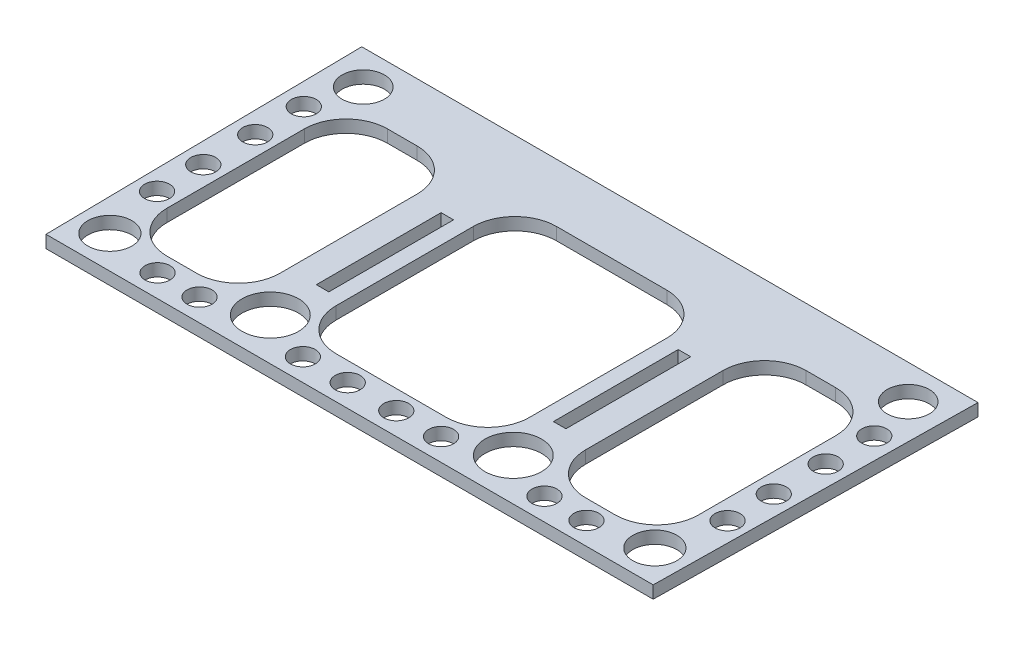
from build123d import *

# Parameters (mm, degrees)
BOSS_EXTRUDE1_DEPTH = 3
CUT_EXTRUDE1_DEPTH  = 10
SKETCH3_W           = 3
SKETCH3_H           = 30
CUT_EXTRUDE2_DEPTH  = 10
SKETCH4_R           = 5.072960447
SKETCH4_R_2         = 3
SKETCH4_R_3         = 5.296326198
SKETCH4_R_4         = 6.795684495
CUT_EXTRUDE3_DEPTH  = 10


with BuildPart() as part:
    # Sketch1 → Boss-Extrude1 (new body)
    with BuildSketch(Plane(origin=(0, 0, 0), x_dir=(1, 0, 0), z_dir=(0, 1, 0))):
        Polygon((-72.98636562, 0), (72.98636562, 0), (74.075, 77), (-74.075, 77), align=None)
    extrude(amount=BOSS_EXTRUDE1_DEPTH)

    # Sketch2 → Cut-Extrude1 (cut)
    with BuildSketch(Plane(origin=(0, 3, 0), x_dir=(1, 0, 0), z_dir=(0, 1, 0))):
        with BuildLine():
            Line((-46.75, 63), (-53.876067096, 63))
            ThreePointArc((-53.876067096, 63), (-60.947134908, 60.071067812), (-63.876067096, 53))
            Line((-63.876067096, 53), (-63.876067096, 20))
            ThreePointArc((-63.876067096, 20), (-60.947134908, 12.928932188), (-53.876067096, 10))
            Line((-53.876067096, 10), (-46.75, 10))
            ThreePointArc((-46.75, 10), (-39.678932188, 12.928932188), (-36.75, 20))
            Line((-36.75, 20), (-36.75, 53))
            ThreePointArc((-36.75, 53), (-39.678932188, 60.071067812), (-46.75, 63))
        make_face()
        with BuildLine():
            Line((-13.25, 63), (0, 63))
            Line((0, 63), (0, 10))
            Line((0, 10), (-13.25, 10))
            ThreePointArc((-13.25, 10), (-20.321067812, 12.928932188), (-23.25, 20))
            Line((-23.25, 20), (-23.25, 53))
            ThreePointArc((-23.25, 53), (-20.321067812, 60.071067812), (-13.25, 63))
        make_face()
    cut_extrude1 = extrude(amount=-CUT_EXTRUDE1_DEPTH, mode=Mode.SUBTRACT)

    # Mirror1: Cut-Extrude1 across plane
    add(cut_extrude1.mirror(Plane(origin=(0, 0, 0), x_dir=(0, 0, 1), z_dir=(1, 0, 0))), mode=Mode.SUBTRACT)

    # Sketch3 → Cut-Extrude2 (cut)
    with BuildSketch(Plane(origin=(0, 3, 0), x_dir=(1, 0, 0), z_dir=(0, 1, 0))):
        with Locations((-28.5, 37)):
            Rectangle(SKETCH3_W, SKETCH3_H)
        with Locations((28.5, 37)):
            Rectangle(SKETCH3_W, SKETCH3_H)
    extrude(amount=-CUT_EXTRUDE2_DEPTH, mode=Mode.SUBTRACT)

    # Sketch4 → Cut-Extrude3 (cut)
    with BuildSketch(Plane(origin=(0, 3, 0), x_dir=(1, 0, 0), z_dir=(0, 1, 0))):
        with Locations((-65.508622451, 68.795423202)):
            Circle(SKETCH4_R)
        with Locations((-68.571363241, 57.565373639)):
            Circle(SKETCH4_R_2)
        with Locations((-68.571363241, 45.881584699)):
            Circle(SKETCH4_R_2)
        with Locations((-68.571363241, 33.403751851)):
            Circle(SKETCH4_R_2)
        with Locations((-68.571363241, 22.287137133)):
            Circle(SKETCH4_R_2)
        with Locations((-51.55613663, 5.385345366)):
            Circle(SKETCH4_R_2)
        with Locations((-41.460435508, 5.385345366)):
            Circle(SKETCH4_R_2)
        with Locations((-16.618204656, 5.385345366)):
            Circle(SKETCH4_R_2)
        with Locations((-5.84189447, 5.385345366)):
            Circle(SKETCH4_R_2)
        with Locations((-65.508622451, 7.880911935)):
            Circle(SKETCH4_R_3)
        with Locations((-29.209472348, 10.149608817)):
            Circle(SKETCH4_R_4)
        with Locations((29.209472348, 10.149608817)):
            Circle(SKETCH4_R_4)
        with Locations((65.508622451, 7.880911935)):
            Circle(SKETCH4_R_3)
        with Locations((5.84189447, 5.385345366)):
            Circle(SKETCH4_R_2)
        with Locations((16.618204656, 5.385345366)):
            Circle(SKETCH4_R_2)
        with Locations((41.460435508, 5.385345366)):
            Circle(SKETCH4_R_2)
        with Locations((51.55613663, 5.385345366)):
            Circle(SKETCH4_R_2)
        with Locations((68.571363241, 22.287137133)):
            Circle(SKETCH4_R_2)
        with Locations((68.571363241, 33.403751851)):
            Circle(SKETCH4_R_2)
        with Locations((68.571363241, 45.881584699)):
            Circle(SKETCH4_R_2)
        with Locations((68.571363241, 57.565373639)):
            Circle(SKETCH4_R_2)
        with Locations((65.508622451, 68.795423202)):
            Circle(SKETCH4_R)
    extrude(amount=-CUT_EXTRUDE3_DEPTH, mode=Mode.SUBTRACT)


solid = part.part
